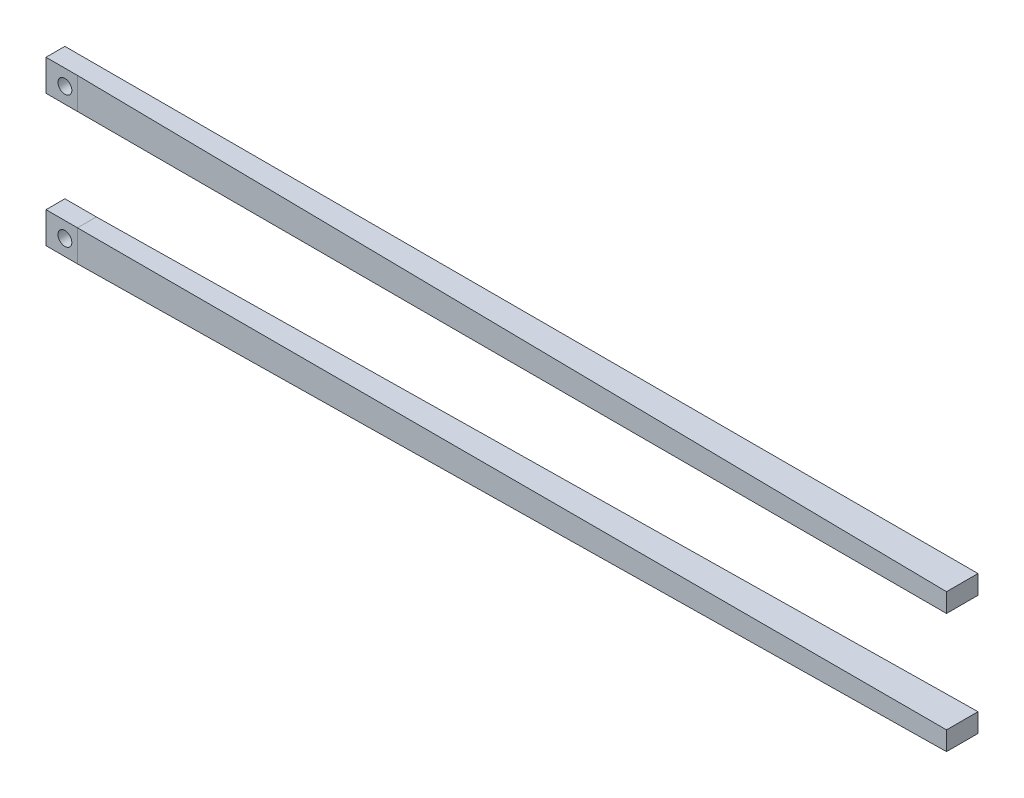
from build123d import *

# Parameters (mm, degrees)
SKIZZE1_W                         = 5
SKIZZE1_H                         = 4.96
AUFSATZ_LINEAR_AUSTRAGEN1_DEPTH   = 3
AUFSATZ_LINEAR_AUSTRAGEN1_2_DEPTH = 3
DURCHGANGSLOCH_F_R_M21_AT_2_COUNT = 2
DURCHGANGSLOCH_F_R_M21_AT_2_PITCH = 20.92
SKIZZE6_W                         = 5
SKIZZE6_H                         = 3
SKIZZE7_W                         = 5
SKIZZE7_H                         = 3


with BuildPart() as part:
    # Skizze1 → Aufsatz-Linear austragen1 (new body)
    with BuildSketch(Plane.XY):
        with Locations((2.5, -2.48)):
            Rectangle(SKIZZE1_W, SKIZZE1_H)
    extrude(amount=AUFSATZ_LINEAR_AUSTRAGEN1_DEPTH)

    # Skizze2 → Durchgangsloch für M21 (revolve, cut)
    with BuildSketch(Plane(origin=(3, -2.5, 3), x_dir=(0, -1, 0), z_dir=(1, 0, 0))):
        Polygon((0, 0), (0, 3.660946681), (1.1, 3), (1.1, 0), align=None)
    durchgangsloch_f_r_m21 = revolve(axis=Axis((3, -2.5, 9.35), (0, 0, -1)), mode=Mode.SUBTRACT)

    # Skizze7 → section 1 of ausformung3
    with BuildSketch(Plane(origin=(145, 0, 0), x_dir=(0, 0, -1), z_dir=(1, 0, 0)), mode=Mode.PRIVATE) as ausformung3_s1:
        with Locations((-2.5, -1.5)):
            Rectangle(SKIZZE7_W, SKIZZE7_H)
    # loft from a face of the part (ausformung3)
    loft([part.faces().sort_by_distance((5, -2.48, 1.5))[0], ausformung3_s1.sketch])


with BuildPart() as body_2:
    # Skizze1 → Aufsatz-Linear austragen1 2 (new body)
    with BuildSketch(Plane.XY):
        with Locations((2.5, -23.44)):
            Rectangle(SKIZZE1_W, SKIZZE1_H)
    extrude(amount=AUFSATZ_LINEAR_AUSTRAGEN1_2_DEPTH)

    # Durchgangsloch für M21 at 2: Durchgangsloch für M21 ×2
    with Locations(*[(0, -i * DURCHGANGSLOCH_F_R_M21_AT_2_PITCH, 0) for i in range(1, DURCHGANGSLOCH_F_R_M21_AT_2_COUNT)]):
        add(durchgangsloch_f_r_m21, mode=Mode.SUBTRACT)

    # Skizze6 → section 1 of ausformung1
    with BuildSketch(Plane(origin=(145, 0, 0), x_dir=(0, 0, -1), z_dir=(1, 0, 0)), mode=Mode.PRIVATE) as ausformung1_s1:
        with Locations((-2.5, -20.5)):
            Rectangle(SKIZZE6_W, SKIZZE6_H)
    # loft from a face of the part (ausformung1)
    loft([body_2.faces().sort_by_distance((5, -23.44, 1.5))[0], ausformung1_s1.sketch])


solid = Compound([part.part, body_2.part])
